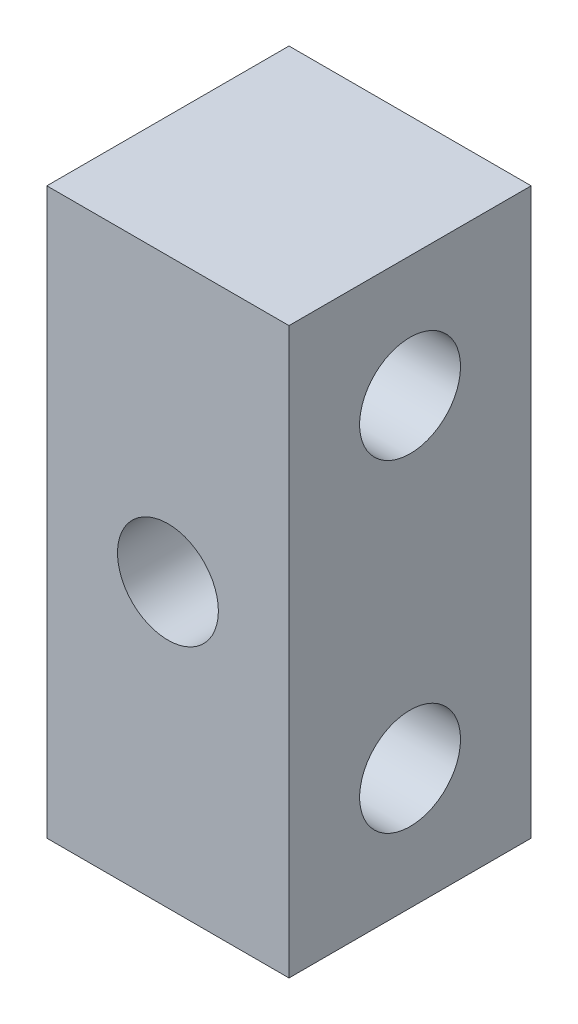
from build123d import *

# Parameters (mm, degrees)
SKETCH_1_W          = 6
SKETCH_1_H          = 14
SKETCH_1_R          = 1.25
EXTRUDE_1_DEPTH     = 6
SKETCH_2_R          = 1.25
CUT_EXTRUDE_1_DEPTH = 7


with BuildPart() as part:
    # 草图1 → 凸台-拉伸1 (new body)
    with BuildSketch(Plane(origin=(0, 0, 0), x_dir=(0, 0, -1), z_dir=(1, 0, 0))):
        Rectangle(SKETCH_1_W, SKETCH_1_H)
        with Locations((0, 4)):
            Circle(SKETCH_1_R, mode=Mode.SUBTRACT)
        with Locations((0, -4)):
            Circle(SKETCH_1_R, mode=Mode.SUBTRACT)
    extrude(amount=EXTRUDE_1_DEPTH)

    # 草图2 → 切除-拉伸1 (cut, through all)
    with BuildSketch(Plane.XY.offset(3)):
        with Locations((3, 0)):
            Circle(SKETCH_2_R)
    extrude(amount=-CUT_EXTRUDE_1_DEPTH, mode=Mode.SUBTRACT)


solid = part.part
